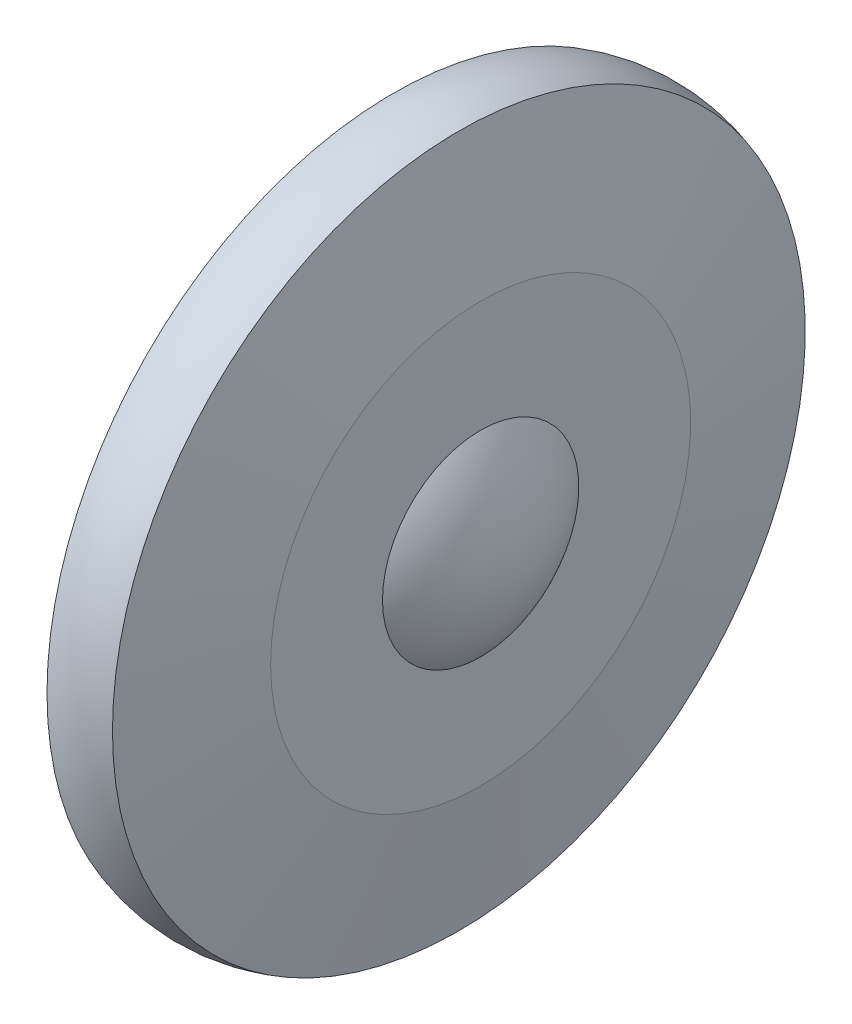
from build123d import *

# Parameters (mm, degrees)
CHAMFER_1_SIZE = 3


with BuildPart() as part:
    # Эскиз1 → Повернуть1 (revolve)
    with BuildSketch(Plane.XY):
        with BuildLine():
            Line((6, 18), (6, 23.5))
            Line((6, 23.5), (-8, 23.5))
            Line((-8, 23.5), (-8, 25.5))
            Line((-8, 25.5), (-9.7, 25.5))
            Line((-9.7, 25.5), (-9.7, 23.5))
            Line((-9.7, 23.5), (-19, 23.5))
            Line((-19, 23.5), (-19, 29.75))
            Line((-19, 29.75), (-10, 29.75))
            Line((-10, 29.75), (-10, 38.5))
            Line((-10, 38.5), (-6, 63.5))
            ThreePointArc((-6, 63.5), (0, 64.5), (6, 63.5))
            Line((6, 63.5), (10, 38.5))
            Line((10, 38.5), (10, 18))
            ThreePointArc((10, 18), (14.460498942, 9.486832981), (16, 0))
            Line((16, 0), (12.907248094, 0))
            ThreePointArc((12.907248094, 0), (11.121156043, 9.639892067), (6, 18))
        make_face()
    revolve(axis=Axis((12.907248094, 0, 0), (1, 0, 0)))

    # Фаска1
    chamfer_1_edges = [part.edges().sort_by_distance(p)[0] for p in [
        (-19, -29.75, 0),
    ]]
    chamfer(chamfer_1_edges, length=CHAMFER_1_SIZE)


solid = part.part
